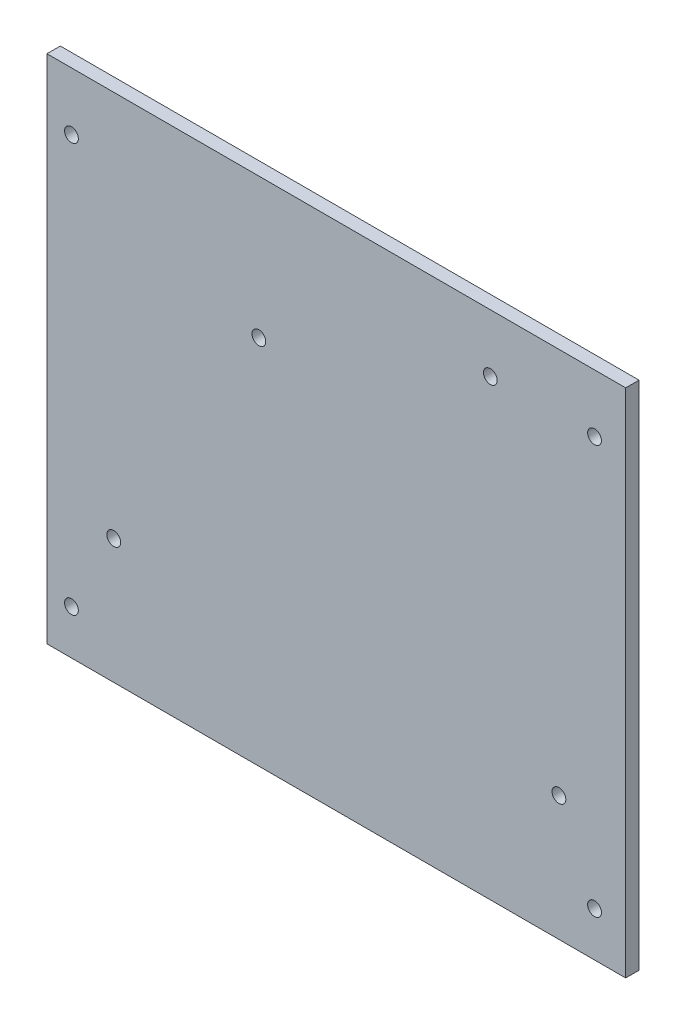
from build123d import *

# Parameters (mm, degrees)
SKETCH1_W           = 130
SKETCH1_H           = 114.8
SKETCH1_R           = 1.55
BOSS_EXTRUDE1_DEPTH = 3
CUT_EXTRUDE1_REACH  = 5
SKETCH3_R           = 1.55
CUT_EXTRUDE2_REACH  = 5
SKETCH4_R           = 1.55


with BuildPart() as part:
    # Sketch1 → Boss-Extrude1 (new body)
    with BuildSketch(Plane.XY):
        Rectangle(SKETCH1_W, SKETCH1_H)
        with Locations((-59.5, 44.4)):
            Circle(SKETCH1_R, mode=Mode.SUBTRACT)
        with Locations((58, 44.4)):
            Circle(SKETCH1_R, mode=Mode.SUBTRACT)
        with Locations((58, -47.4)):
            Circle(SKETCH1_R, mode=Mode.SUBTRACT)
        with Locations((-59.5, -47.4)):
            Circle(SKETCH1_R, mode=Mode.SUBTRACT)
    extrude(amount=BOSS_EXTRUDE1_DEPTH)

    # Sketch3 → Cut-Extrude1 (cut, up to next)
    with BuildSketch(Plane(origin=(0, 0, 0), x_dir=(-1, 0, 0), z_dir=(0, 0, -1)), mode=Mode.PRIVATE) as cut_extrude1_sk1:
        with Locations((-50, -29.4)):
            Circle(SKETCH3_R)
    cut_extrude1_tool1 = extrude(cut_extrude1_sk1.sketch, amount=-CUT_EXTRUDE1_REACH, mode=Mode.PRIVATE) & part.part
    add(cut_extrude1_tool1.solids().sort_by_distance((50, -29.4, 0))[0], mode=Mode.SUBTRACT)
    # Sketch3 → Cut-Extrude1 (cut, up to next)
    with BuildSketch(Plane(origin=(0, 0, 0), x_dir=(-1, 0, 0), z_dir=(0, 0, -1)), mode=Mode.PRIVATE) as cut_extrude1_sk2:
        with Locations((50, -29.4)):
            Circle(SKETCH3_R)
    cut_extrude1_tool2 = extrude(cut_extrude1_sk2.sketch, amount=-CUT_EXTRUDE1_REACH, mode=Mode.PRIVATE) & part.part
    add(cut_extrude1_tool2.solids().sort_by_distance((-50, -29.4, 0))[0], mode=Mode.SUBTRACT)

    # Sketch4 → Cut-Extrude2 (cut, up to next)
    with BuildSketch(Plane(origin=(0, 0, 0), x_dir=(-1, 0, 0), z_dir=(0, 0, -1)), mode=Mode.PRIVATE) as cut_extrude2_sk1:
        with Locations((-34.6, 44.4)):
            Circle(SKETCH4_R)
    cut_extrude2_tool1 = extrude(cut_extrude2_sk1.sketch, amount=-CUT_EXTRUDE2_REACH, mode=Mode.PRIVATE) & part.part
    add(cut_extrude2_tool1.solids().sort_by_distance((34.6, 44.4, 0))[0], mode=Mode.SUBTRACT)
    # Sketch4 → Cut-Extrude2 (cut, up to next)
    with BuildSketch(Plane(origin=(0, 0, 0), x_dir=(-1, 0, 0), z_dir=(0, 0, -1)), mode=Mode.PRIVATE) as cut_extrude2_sk2:
        with Locations((17.4, 25.96)):
            Circle(SKETCH4_R)
    cut_extrude2_tool2 = extrude(cut_extrude2_sk2.sketch, amount=-CUT_EXTRUDE2_REACH, mode=Mode.PRIVATE) & part.part
    add(cut_extrude2_tool2.solids().sort_by_distance((-17.4, 25.96, 0))[0], mode=Mode.SUBTRACT)


solid = part.part
